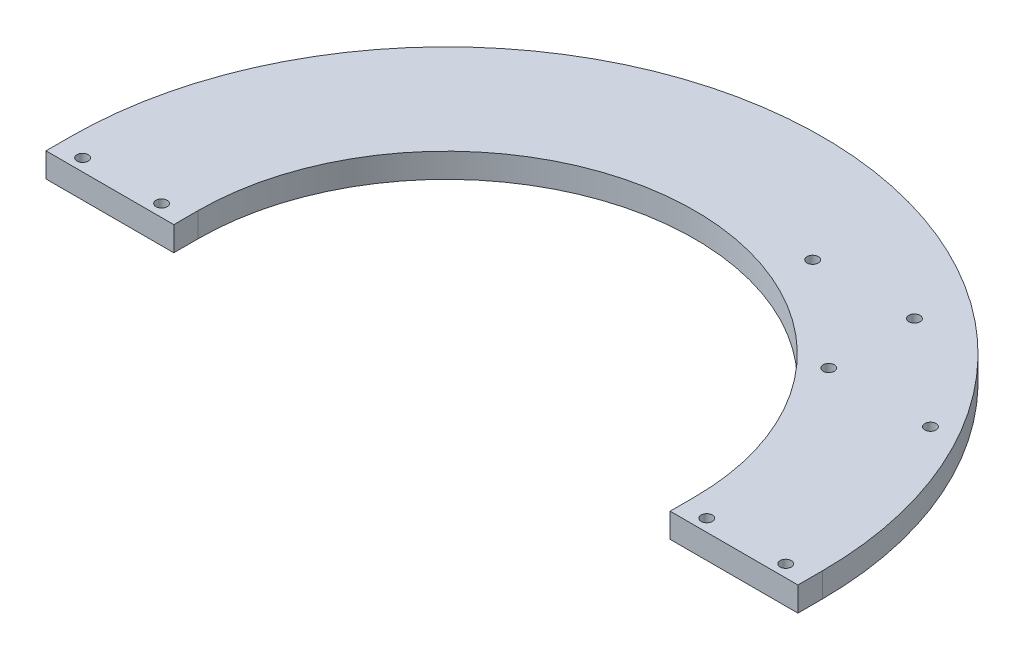
from build123d import *

# Parameters (mm, degrees)
BOSS_EXTRUDE1_DEPTH = 7.62
CUT_EXTRUDE1_REACH  = 9.62
SKETCH3_R           = 1.7526


with BuildPart() as part:
    # Sketch1 → Boss-Extrude1 (new body)
    with BuildSketch(Plane(origin=(0, 0, 0), x_dir=(1, 0, 0), z_dir=(0, 1, 0))):
        with BuildLine():
            Line((-117.31625, 0), (-117.31625, -7.62))
            Line((-117.31625, -7.62), (-77.43825, -7.62))
            Line((-77.43825, -7.62), (-77.43825, 0))
            ThreePointArc((-77.43825, 0), (0, 77.43825), (77.43825, 0))
            Line((77.43825, 0), (77.43825, -7.62))
            Line((77.43825, -7.62), (117.31625, -7.62))
            Line((117.31625, -7.62), (117.31625, 0))
            ThreePointArc((117.31625, 0), (0, 117.31625), (-117.31625, 0))
        make_face()
    extrude(amount=BOSS_EXTRUDE1_DEPTH)

    # Sketch3 → Cut-Extrude1 (cut, up to next)
    with BuildSketch(Plane(origin=(0, 7.62, 0), x_dir=(1, 0, 0), z_dir=(0, 1, 0)), mode=Mode.PRIVATE) as cut_extrude1_sk1:
        with Locations((-109.69625, -3.81)):
            Circle(SKETCH3_R)
    cut_extrude1_tool1 = extrude(cut_extrude1_sk1.sketch, amount=-CUT_EXTRUDE1_REACH, mode=Mode.PRIVATE) & part.part
    add(cut_extrude1_tool1.solids().sort_by_distance((-109.69625, 7.62, 3.81))[0], mode=Mode.SUBTRACT)
    # Sketch3 → Cut-Extrude1 (cut, up to next)
    with BuildSketch(Plane(origin=(0, 7.62, 0), x_dir=(1, 0, 0), z_dir=(0, 1, 0)), mode=Mode.PRIVATE) as cut_extrude1_sk2:
        with Locations((-85.05825, -3.81)):
            Circle(SKETCH3_R)
    cut_extrude1_tool2 = extrude(cut_extrude1_sk2.sketch, amount=-CUT_EXTRUDE1_REACH, mode=Mode.PRIVATE) & part.part
    add(cut_extrude1_tool2.solids().sort_by_distance((-85.05825, 7.62, 3.81))[0], mode=Mode.SUBTRACT)
    # Sketch3 → Cut-Extrude1 (cut, up to next)
    with BuildSketch(Plane(origin=(0, 7.62, 0), x_dir=(1, 0, 0), z_dir=(0, 1, 0)), mode=Mode.PRIVATE) as cut_extrude1_sk3:
        with Locations((85.05825, -3.81)):
            Circle(SKETCH3_R)
    cut_extrude1_tool3 = extrude(cut_extrude1_sk3.sketch, amount=-CUT_EXTRUDE1_REACH, mode=Mode.PRIVATE) & part.part
    add(cut_extrude1_tool3.solids().sort_by_distance((85.05825, 7.62, 3.81))[0], mode=Mode.SUBTRACT)
    # Sketch3 → Cut-Extrude1 (cut, up to next)
    with BuildSketch(Plane(origin=(0, 7.62, 0), x_dir=(1, 0, 0), z_dir=(0, 1, 0)), mode=Mode.PRIVATE) as cut_extrude1_sk4:
        with Locations((109.69625, -3.81)):
            Circle(SKETCH3_R)
    cut_extrude1_tool4 = extrude(cut_extrude1_sk4.sketch, amount=-CUT_EXTRUDE1_REACH, mode=Mode.PRIVATE) & part.part
    add(cut_extrude1_tool4.solids().sort_by_distance((109.69625, 7.62, 3.81))[0], mode=Mode.SUBTRACT)
    # Sketch3 → Cut-Extrude1 (cut, up to next)
    with BuildSketch(Plane(origin=(0, 7.62, 0), x_dir=(1, 0, 0), z_dir=(0, 1, 0)), mode=Mode.PRIVATE) as cut_extrude1_sk5:
        with Locations((31.75, 82.55)):
            Circle(SKETCH3_R)
    cut_extrude1_tool5 = extrude(cut_extrude1_sk5.sketch, amount=-CUT_EXTRUDE1_REACH, mode=Mode.PRIVATE) & part.part
    add(cut_extrude1_tool5.solids().sort_by_distance((31.75, 7.62, -82.55))[0], mode=Mode.SUBTRACT)
    # Sketch3 → Cut-Extrude1 (cut, up to next)
    with BuildSketch(Plane(origin=(0, 7.62, 0), x_dir=(1, 0, 0), z_dir=(0, 1, 0)), mode=Mode.PRIVATE) as cut_extrude1_sk6:
        with Locations((63.5, 82.55)):
            Circle(SKETCH3_R)
    cut_extrude1_tool6 = extrude(cut_extrude1_sk6.sketch, amount=-CUT_EXTRUDE1_REACH, mode=Mode.PRIVATE) & part.part
    add(cut_extrude1_tool6.solids().sort_by_distance((63.5, 7.62, -82.55))[0], mode=Mode.SUBTRACT)
    # Sketch3 → Cut-Extrude1 (cut, up to next)
    with BuildSketch(Plane(origin=(0, 7.62, 0), x_dir=(1, 0, 0), z_dir=(0, 1, 0)), mode=Mode.PRIVATE) as cut_extrude1_sk7:
        with Locations((63.5, 55.812428263)):
            Circle(SKETCH3_R)
    cut_extrude1_tool7 = extrude(cut_extrude1_sk7.sketch, amount=-CUT_EXTRUDE1_REACH, mode=Mode.PRIVATE) & part.part
    add(cut_extrude1_tool7.solids().sort_by_distance((63.5, 7.62, -55.812428))[0], mode=Mode.SUBTRACT)
    # Sketch3 → Cut-Extrude1 (cut, up to next)
    with BuildSketch(Plane(origin=(0, 7.62, 0), x_dir=(1, 0, 0), z_dir=(0, 1, 0)), mode=Mode.PRIVATE) as cut_extrude1_sk8:
        with Locations((95.25, 55.812428263)):
            Circle(SKETCH3_R)
    cut_extrude1_tool8 = extrude(cut_extrude1_sk8.sketch, amount=-CUT_EXTRUDE1_REACH, mode=Mode.PRIVATE) & part.part
    add(cut_extrude1_tool8.solids().sort_by_distance((95.25, 7.62, -55.812428))[0], mode=Mode.SUBTRACT)


solid = part.part
